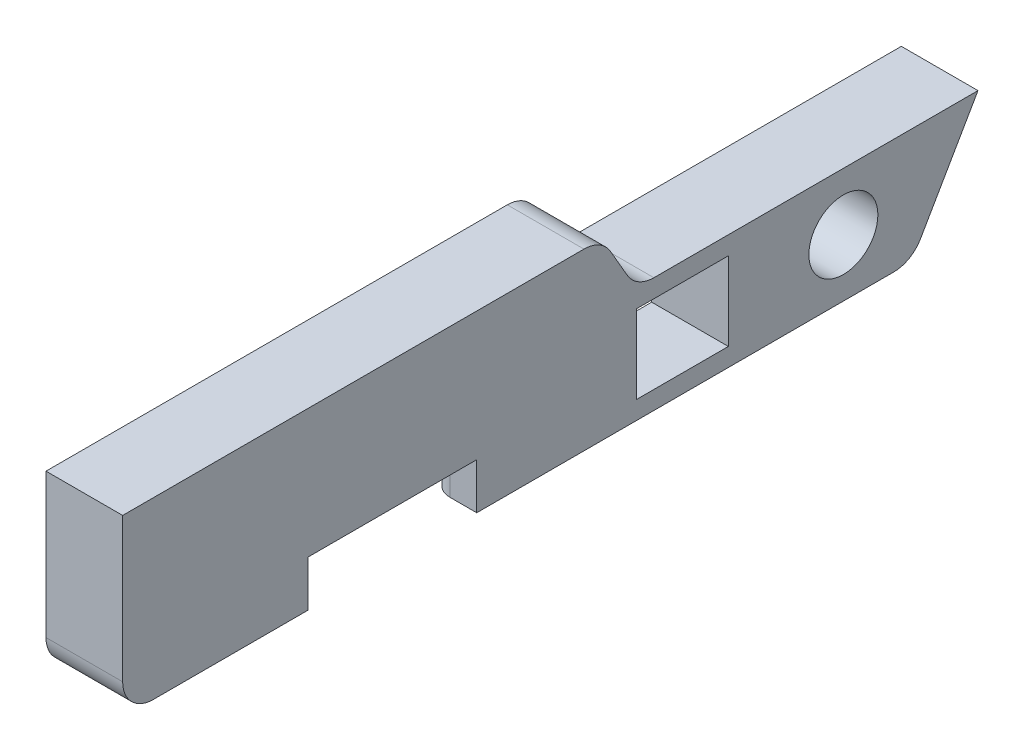
from build123d import *

# Parameters (mm, degrees)
BOSS_EXTRUDE1_DEPTH = 6.35
SKETCH2_R           = 2.8575
SKETCH2_W           = 7.62
SKETCH2_H           = 6.5024
SKETCH2_W_2         = 13.97
SKETCH2_H_2         = 3.81
CUT_EXTRUDE1_DEPTH  = 7.35
SKETCH3_W           = 5.334
SKETCH3_H           = 5.08
CUT_EXTRUDE2_DEPTH  = 13.97
SKETCH4_W           = 24.13
SKETCH4_H           = 11.681664872
CUT_EXTRUDE3_DEPTH  = 2.54
FILLET1_R           = 1.5875


with BuildPart() as part:
    # Sketch1 → Boss-Extrude1 (new body)
    with BuildSketch(Plane(origin=(0, 0, 0), x_dir=(0, 0, -1), z_dir=(1, 0, 0))):
        with BuildLine():
            Line((0, 2.54), (0, 14.474335183))
            Line((0, 14.474335183), (38.205942443, 14.474335183))
            ThreePointArc((38.205942443, 14.474335183), (39.475942443, 14.134039708), (40.405646968, 13.204335183))
            Line((40.405646968, 13.204335183), (41.796677285, 10.795))
            ThreePointArc((41.796677285, 10.795), (42.72638181, 9.865295474), (43.99638181, 9.525))
            Line((43.99638181, 9.525), (70.840761314, 9.525))
            Line((70.840761314, 9.525), (66.074734842, 1.27))
            ThreePointArc((66.074734842, 1.27), (65.145030316, 0.340295474), (63.875030316, 0))
            Line((63.875030316, 0), (2.54, 0))
            ThreePointArc((2.54, 0), (0.743948776, 0.743948776), (0, 2.54))
        make_face()
    extrude(amount=BOSS_EXTRUDE1_DEPTH)

    # Sketch2 → Cut-Extrude1 (cut, through all)
    with BuildSketch(Plane(origin=(6.35, 0, 0), x_dir=(0, 0, -1), z_dir=(1, 0, 0))):
        with Locations((59.69, 4.7625)):
            Circle(SKETCH2_R)
        with Locations((46.355, 4.7625)):
            Rectangle(SKETCH2_W, SKETCH2_H)
        with Locations((22.3393, 1.905)):
            Rectangle(SKETCH2_W_2, SKETCH2_H_2)
    extrude(amount=-CUT_EXTRUDE1_DEPTH, mode=Mode.SUBTRACT)

    # Sketch3 → Cut-Extrude2 (cut)
    with BuildSketch(Plane.XY.offset(-29.3243)):
        with Locations((2.667, 6.35)):
            Rectangle(SKETCH3_W, SKETCH3_H)
    extrude(amount=CUT_EXTRUDE2_DEPTH, mode=Mode.SUBTRACT)

    # Sketch4 → Cut-Extrude3 (cut)
    with BuildSketch(Plane(origin=(0, 0, 0), x_dir=(0, 0, -1), z_dir=(1, 0, 0))):
        with Locations((21.0693, 5.840832436)):
            Rectangle(SKETCH4_W, SKETCH4_H)
    extrude(amount=CUT_EXTRUDE3_DEPTH, mode=Mode.SUBTRACT)

    # Fillet1
    fillet1_edges = [part.edges().sort_by_distance(p)[0] for p in [
        (2.54, 8.89, -22.3393),
        (2.54, 4.445, -15.3543),
        (2.54, 4.445, -29.3243),
        (0, 5.840832436, -9.0043),
        (0, 5.840832436, -33.1343),
        (0, 11.681664872, -21.0693),
    ]]
    fillet(fillet1_edges, radius=FILLET1_R)


solid = part.part
